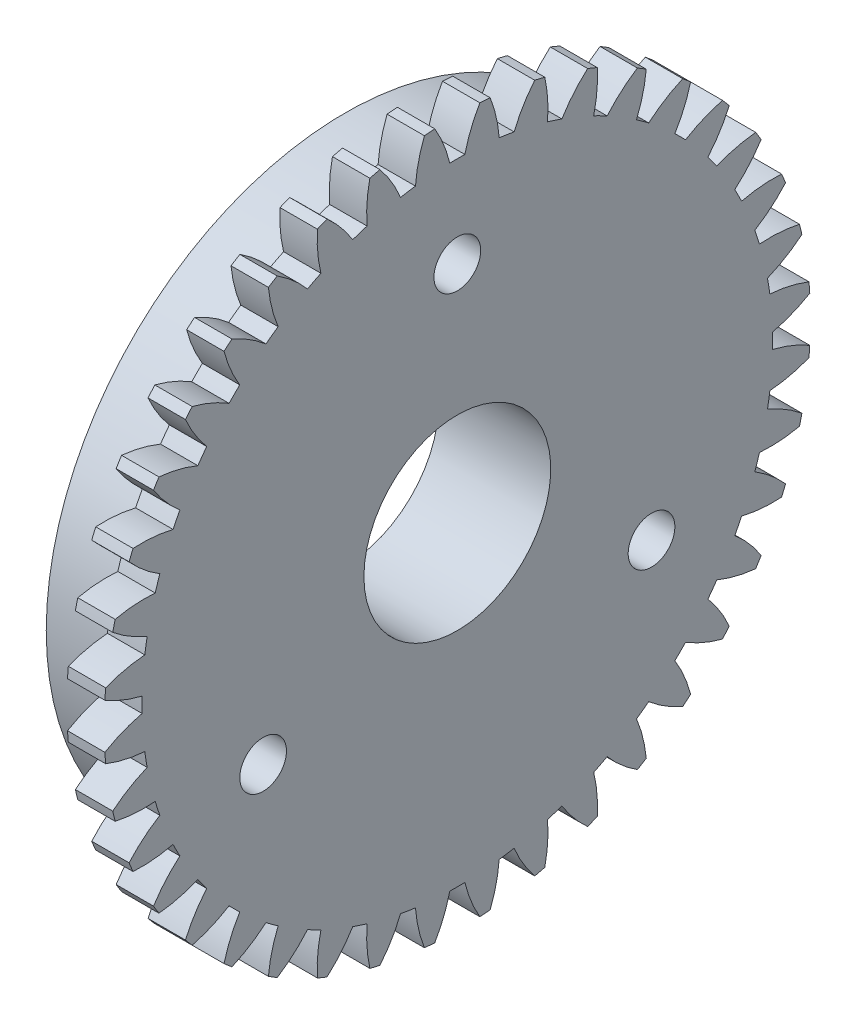
from build123d import *

# Parameters (mm, degrees)
BASPROSKE_W               = 2
BASPROSKE_H               = 18.9
TOOTHCUT_DEPTH            = 27.803357999
TEETHCUTS_COUNT           = 40
TEETHCUTS_ANGLE           = 351
HUBNEAONESKE_R            = 16
HUBNEARONE_DEPTH          = 4.0000508
BORSKE_R                  = 3
BORE_DEPTH                = 6.0000508
SKETCH1_R                 = 5
CUT_EXTRUDE1_DEPTH        = 28.340674698
F_2_5MM_DOWEL_HOLE1_D     = 2.5
F_2_5MM_DOWEL_HOLE1_DEPTH = 10
F_2_5MM_DOWEL_HOLE1_TIP   = 0.751075774


with BuildPart() as part:
    # BasProSke → Base-Revolve (revolve)
    with BuildSketch(Plane(origin=(0, 0, 0), x_dir=(1, 0, 0), z_dir=(0, 1, 0)), mode=Mode.PRIVATE) as base_revolve_sk:
        with Locations((1, 9.45)):
            Rectangle(BASPROSKE_W, BASPROSKE_H)
    revolve(base_revolve_sk.sketch.rotate(Axis((-10, 0, 0), (1, 0, 0)), 180), axis=Axis((-10, 0, 0), (1, 0, 0)))

    # TooCutSke → ToothCut (cut, through all)
    with BuildSketch(Plane(origin=(0, 0, 0), x_dir=(0, 0, -1), z_dir=(1, 0, 0))):
        with BuildLine():
            ThreePointArc((0.403454095, 16.869176056), (0, 16.874), (-0.403454095, 16.869176056))
            ThreePointArc((-0.403454095, 16.869176056), (-0.735275667, 17.908633598), (-1.220360302, 18.88601297))
            ThreePointArc((-1.220360302, 18.88601297), (0, 18.9254), (1.220360302, 18.88601297))
            ThreePointArc((1.220360302, 18.88601297), (0.735275667, 17.908633598), (0.403454095, 16.869176056))
        make_face()
    toothcut = extrude(amount=TOOTHCUT_DEPTH, mode=Mode.SUBTRACT)

    # TeethCuts: ToothCut ×40 about axis
    teethcuts_axis = Axis((-10, 0, 0), (1, 0, 0))
    for i in range(1, TEETHCUTS_COUNT):
        add(toothcut.rotate(teethcuts_axis, i * TEETHCUTS_ANGLE / (TEETHCUTS_COUNT - 1)), mode=Mode.SUBTRACT)

    # HubNeaOneSke → HubNearOne (add)
    with BuildSketch(Plane.ZY):
        with Locations(Location((0, 0, 0), (0, 0, 180))):
            Circle(HUBNEAONESKE_R)
    extrude(amount=HUBNEARONE_DEPTH)

    # BorSke → Bore (cut, symmetric)
    with BuildSketch(Plane(origin=(0, 0, 0), x_dir=(0, 0, -1), z_dir=(1, 0, 0))):
        with Locations(Location((0, 0, 0), (0, 0, 180))):
            Circle(BORSKE_R)
    extrude(amount=BORE_DEPTH, both=True, mode=Mode.SUBTRACT)

    # Sketch1 → Cut-Extrude1 (cut, through all)
    with BuildSketch(Plane.ZY.offset(4.0000508)):
        Circle(SKETCH1_R)
    extrude(amount=-CUT_EXTRUDE1_DEPTH, mode=Mode.SUBTRACT)

    # Ø2.5mm Dowel Hole1
    with Locations(Plane.ZY.offset(4.0000508)):
        with Locations((0, 12), (10.392304845, -6), (-10.392304845, -6)):
            Hole(F_2_5MM_DOWEL_HOLE1_D / 2, depth=F_2_5MM_DOWEL_HOLE1_DEPTH)
            with Locations((0, 0, -(F_2_5MM_DOWEL_HOLE1_DEPTH + F_2_5MM_DOWEL_HOLE1_TIP / 2))):  # 118° drill point
                Cone(0, F_2_5MM_DOWEL_HOLE1_D / 2, F_2_5MM_DOWEL_HOLE1_TIP, mode=Mode.SUBTRACT)


solid = part.part
